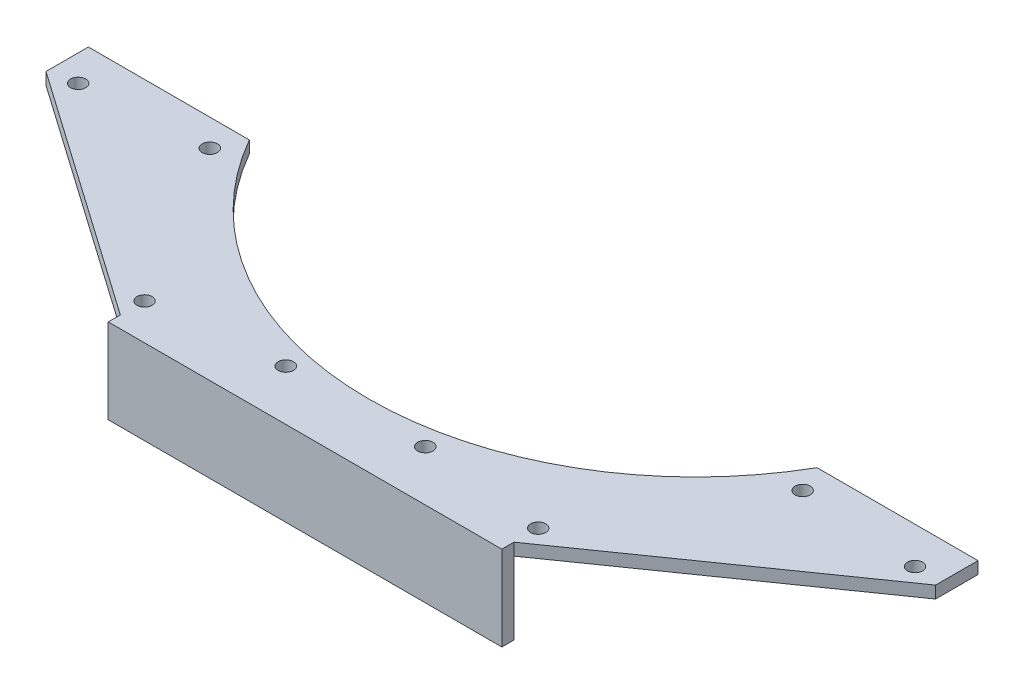
from build123d import *

# Parameters (mm, degrees)
SKETCH1_R           = 1.6
SKETCH1_R_2         = 1.5875
BOSS_EXTRUDE1_DEPTH = 2.54
SKETCH2_W           = 82.55
SKETCH2_H           = 17.78
BOSS_EXTRUDE2_DEPTH = 2.54


with BuildPart() as part:
    # Sketch1 → Boss-Extrude1 (new body)
    with BuildSketch(Plane(origin=(0, 10.380200841, 0), x_dir=(1, 0, 0), z_dir=(0, 1, 0))):
        with BuildLine():
            Line((-38.220672856, -111.749766717), (-120.770672856, -111.749766717))
            Line((-120.770672856, -111.749766717), (-172.786827669, -75.327663008))
            Line((-172.786827669, -75.327663008), (-172.786827669, -66.437663008))
            Line((-172.786827669, -66.437663008), (-139.027490416, -66.437663008))
            ThreePointArc((-139.027490416, -66.437663008), (-79.495672856, -100.970943664), (-19.963855297, -66.437663008))
            Line((-19.963855297, -66.437663008), (13.795481956, -66.437663008))
            Line((13.795481956, -66.437663008), (13.795481956, -75.327663008))
            Line((13.795481956, -75.327663008), (-38.220672856, -111.749766717))
        make_face()
        with Locations((-17.327095379, -72.094107722)):
            Circle(SKETCH1_R, mode=Mode.SUBTRACT)
        with Locations((-141.664250334, -72.094107722)):
            Circle(SKETCH1_R, mode=Mode.SUBTRACT)
        with Locations((-94.127447008, -103.699839694)):
            Circle(SKETCH1_R, mode=Mode.SUBTRACT)
        with Locations((-64.863898705, -103.699839694)):
            Circle(SKETCH1_R, mode=Mode.SUBTRACT)
        with Locations((-120.770672856, -106.669766717)):
            Circle(SKETCH1_R_2, mode=Mode.SUBTRACT)
        with Locations((-167.256455611, -74.120071212)):
            Circle(SKETCH1_R_2, mode=Mode.SUBTRACT)
        with Locations((8.265109898, -74.120071212)):
            Circle(SKETCH1_R_2, mode=Mode.SUBTRACT)
        with Locations((-38.220672856, -106.669766717)):
            Circle(SKETCH1_R_2, mode=Mode.SUBTRACT)
    extrude(amount=BOSS_EXTRUDE1_DEPTH)

    # Sketch2 → Boss-Extrude2 (add)
    with BuildSketch(Plane.XY.offset(111.749766717)):
        with Locations((-79.495672856, 4.030200841)):
            Rectangle(SKETCH2_W, SKETCH2_H)
    extrude(amount=BOSS_EXTRUDE2_DEPTH)


solid = part.part
